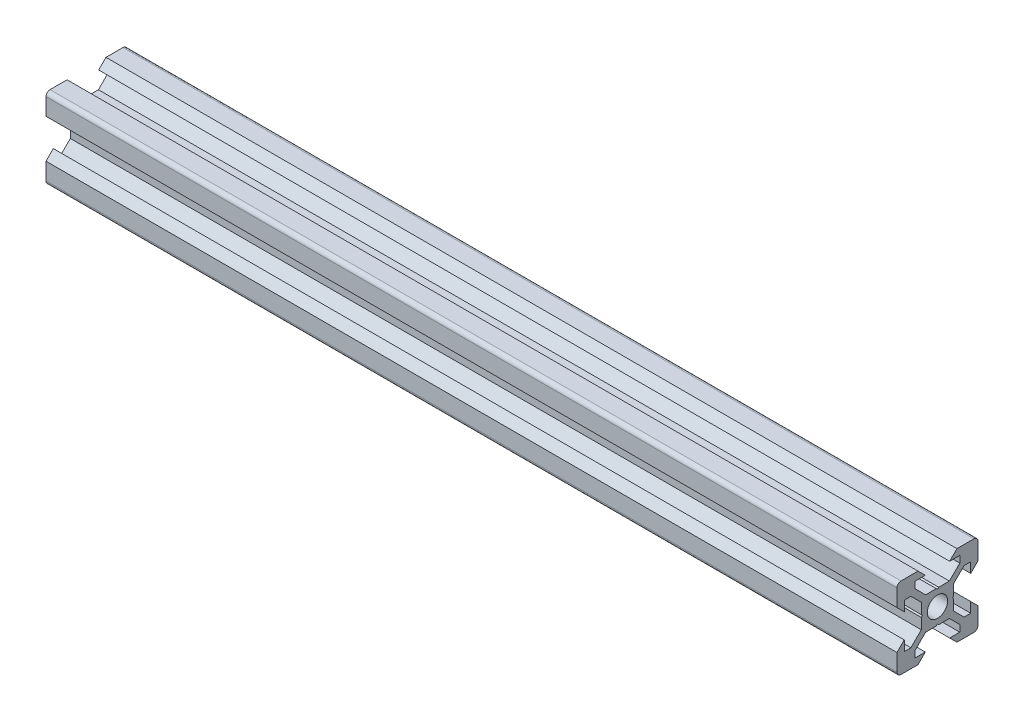
from build123d import *

# Parameters (mm, degrees)
SKETCH11_R                                  = 2.5
QUADRADO_PF20_11_PERFIL_2020_V_SLOT_1_DEPTH = 210


with BuildPart() as part:
    # Sketch11 → Quadrado PF20-11 - PERFIL 2020 V-SLOT(1) (new body)
    with BuildSketch(Plane.YZ):
        with BuildLine():
            Line((-4.8, 10), (-3, 8.2))
            Line((-3, 8.2), (-5.5, 8.2))
            Line((-5.5, 8.2), (-5.5, 6.560660172))
            Line((-5.5, 6.560660172), (-2.939339828, 4))
            Line((-2.939339828, 4), (-0.3, 4))
            Line((-0.3, 4), (0, 3.7))
            Line((0, 3.7), (0.3, 4))
            Line((0.3, 4), (2.939339828, 4))
            Line((2.939339828, 4), (5.5, 6.560660172))
            Line((5.5, 6.560660172), (5.5, 8.2))
            Line((5.5, 8.2), (3, 8.2))
            Line((3, 8.2), (4.8, 10))
            Line((4.8, 10), (9, 10))
            ThreePointArc((9, 10), (9.707106781, 9.707106781), (10, 9))
            Line((10, 9), (10, 4.8))
            Line((10, 4.8), (8.2, 3))
            Line((8.2, 3), (8.2, 5.5))
            Line((8.2, 5.5), (6.560660172, 5.5))
            Line((6.560660172, 5.5), (4, 2.939339828))
            Line((4, 2.939339828), (4, 0.3))
            Line((4, 0.3), (3.7, 0))
            Line((3.7, 0), (4, -0.3))
            Line((4, -0.3), (4, -2.939339828))
            Line((4, -2.939339828), (6.560660172, -5.5))
            Line((6.560660172, -5.5), (8.2, -5.5))
            Line((8.2, -5.5), (8.2, -3))
            Line((8.2, -3), (10, -4.8))
            Line((10, -4.8), (10, -9))
            ThreePointArc((10, -9), (9.707106781, -9.707106781), (9, -10))
            Line((9, -10), (4.8, -10))
            Line((4.8, -10), (3, -8.2))
            Line((3, -8.2), (5.5, -8.2))
            Line((5.5, -8.2), (5.5, -6.560660172))
            Line((5.5, -6.560660172), (2.939339828, -4))
            Line((2.939339828, -4), (0.3, -4))
            Line((0.3, -4), (0, -3.7))
            Line((0, -3.7), (-0.3, -4))
            Line((-0.3, -4), (-2.939339828, -4))
            Line((-2.939339828, -4), (-5.5, -6.560660172))
            Line((-5.5, -6.560660172), (-5.5, -8.2))
            Line((-5.5, -8.2), (-3, -8.2))
            Line((-3, -8.2), (-4.8, -10))
            Line((-4.8, -10), (-9, -10))
            ThreePointArc((-9, -10), (-9.707106781, -9.707106781), (-10, -9))
            Line((-10, -9), (-10, -4.8))
            Line((-10, -4.8), (-8.2, -3))
            Line((-8.2, -3), (-8.2, -5.5))
            Line((-8.2, -5.5), (-6.560660172, -5.5))
            Line((-6.560660172, -5.5), (-4, -2.939339828))
            Line((-4, -2.939339828), (-4, -0.3))
            Line((-4, -0.3), (-3.7, 0))
            Line((-3.7, 0), (-4, 0.3))
            Line((-4, 0.3), (-4, 2.939339828))
            Line((-4, 2.939339828), (-6.560660172, 5.5))
            Line((-6.560660172, 5.5), (-8.2, 5.5))
            Line((-8.2, 5.5), (-8.2, 3))
            Line((-8.2, 3), (-10, 4.8))
            Line((-10, 4.8), (-10, 9))
            ThreePointArc((-10, 9), (-9.707106781, 9.707106781), (-9, 10))
            Line((-9, 10), (-4.8, 10))
        make_face()
        Circle(SKETCH11_R, mode=Mode.SUBTRACT)
    extrude(amount=QUADRADO_PF20_11_PERFIL_2020_V_SLOT_1_DEPTH)


solid = part.part
